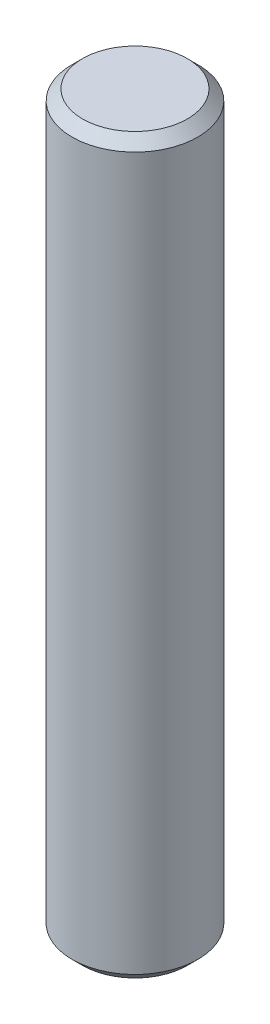
from build123d import *

# Parameters (mm, degrees)
SKETCH1_R           = 6
BOSS_EXTRUDE1_DEPTH = 35
CHAMFER1_SIZE       = 1


with BuildPart() as part:
    # Sketch1 → Boss-Extrude1 (new body, symmetric)
    with BuildSketch(Plane(origin=(0, 0, 0), x_dir=(1, 0, 0), z_dir=(0, 1, 0))):
        Circle(SKETCH1_R)
    extrude(amount=BOSS_EXTRUDE1_DEPTH, both=True)

    # Chamfer1
    chamfer1_edges = [part.edges().sort_by_distance(p)[0] for p in [
        (-6, -35, 0),
        (-6, 35, 0),
    ]]
    chamfer(chamfer1_edges, length=CHAMFER1_SIZE)


solid = part.part
